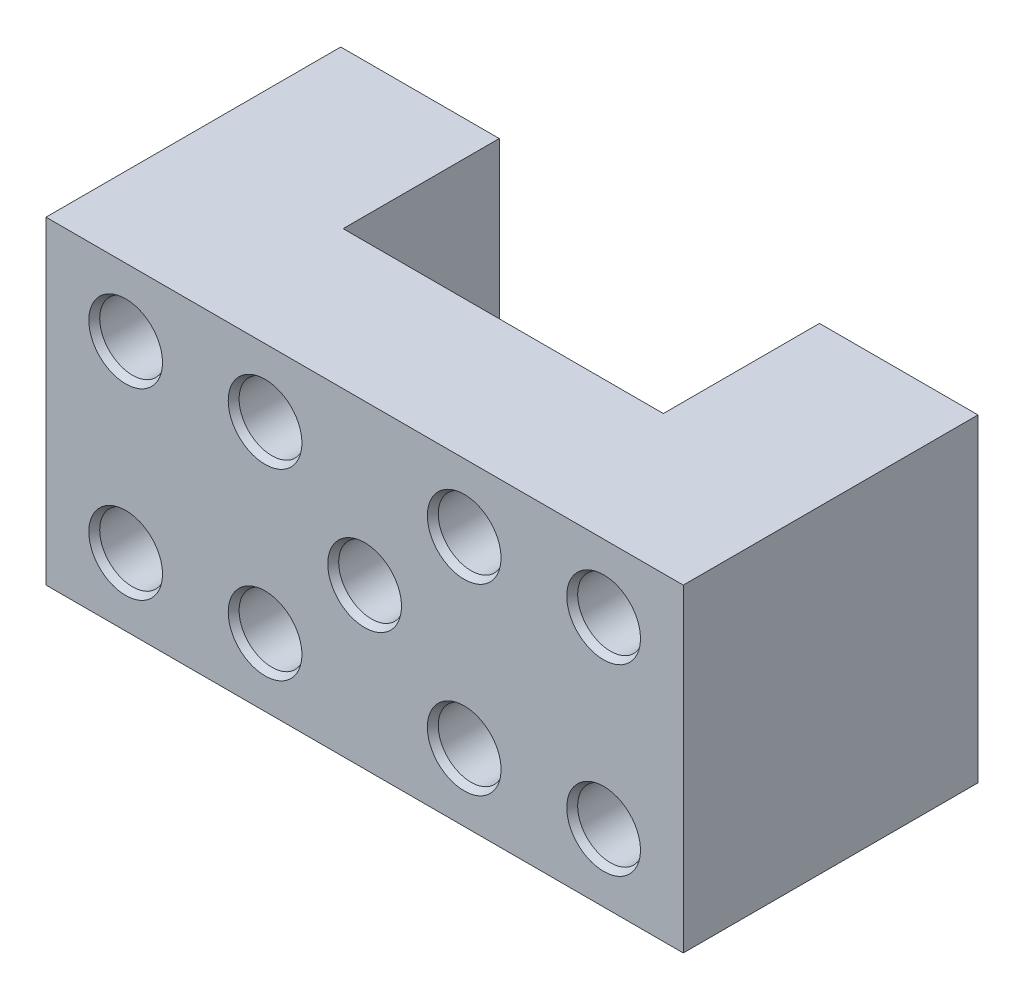
from build123d import *

# Parameters (mm, degrees)
BOSS_EXTRUDE2_DEPTH = 40
SKETCH3_R           = 4.125
CUT_EXTRUDE1_DEPTH  = 38
CHAMFER1_SIZE       = 0.5
CHAMFER1_SIZE2      = 0.866025404


with BuildPart() as part:
    # Sketch2 → Boss-Extrude2 (new body)
    with BuildSketch(Plane(origin=(0, 0, 0), x_dir=(1, 0, 0), z_dir=(0, 1, 0))):
        Polygon((-31.312103746, 37), (-31.312103746, 0), (48.687896254, 0), (48.687896254, 37), (28.787896254, 37), (28.787896254, 17.4), (-11.412103746, 17.4), (-11.412103746, 37), align=None)
    extrude(amount=BOSS_EXTRUDE2_DEPTH)

    # Sketch3 → Cut-Extrude1 (cut, through all)
    with BuildSketch(Plane.XY):
        with Locations((-3.812103746, 31.5)):
            Circle(SKETCH3_R)
        with Locations((21.187896254, 31.5)):
            Circle(SKETCH3_R)
        with Locations((21.187896254, 8.5)):
            Circle(SKETCH3_R)
        with Locations((-3.812103746, 8.5)):
            Circle(SKETCH3_R)
        with Locations((-21.312103746, 31.5)):
            Circle(SKETCH3_R)
        with Locations((38.687896254, 31.5)):
            Circle(SKETCH3_R)
        with Locations((38.687896254, 8.5)):
            Circle(SKETCH3_R)
        with Locations((-21.312103746, 8.5)):
            Circle(SKETCH3_R)
        with Locations((8.687896254, 20)):
            Circle(SKETCH3_R)
    extrude(amount=-CUT_EXTRUDE1_DEPTH, mode=Mode.SUBTRACT)

    # Chamfer1
    chamfer1_edges = [part.edges().sort_by_distance(p)[0] for p in [
        (-7.937103746, 31.5, 0),
        (4.562896254, 20, 0),
        (-25.437103746, 8.5, 0),
        (34.562896254, 8.5, 0),
        (34.562896254, 31.5, 0),
        (-25.437103746, 31.5, 0),
        (-7.937103746, 8.5, 0),
        (17.062896254, 8.5, 0),
        (17.062896254, 31.5, 0),
    ]]
    chamfer1_side = [part.faces().sort_by_distance(p)[0] for p in [
        (-30.417676555, 20, 0),
    ]]
    chamfer(chamfer1_edges, length=CHAMFER1_SIZE, length2=CHAMFER1_SIZE2, reference=chamfer1_side[0])


solid = part.part
